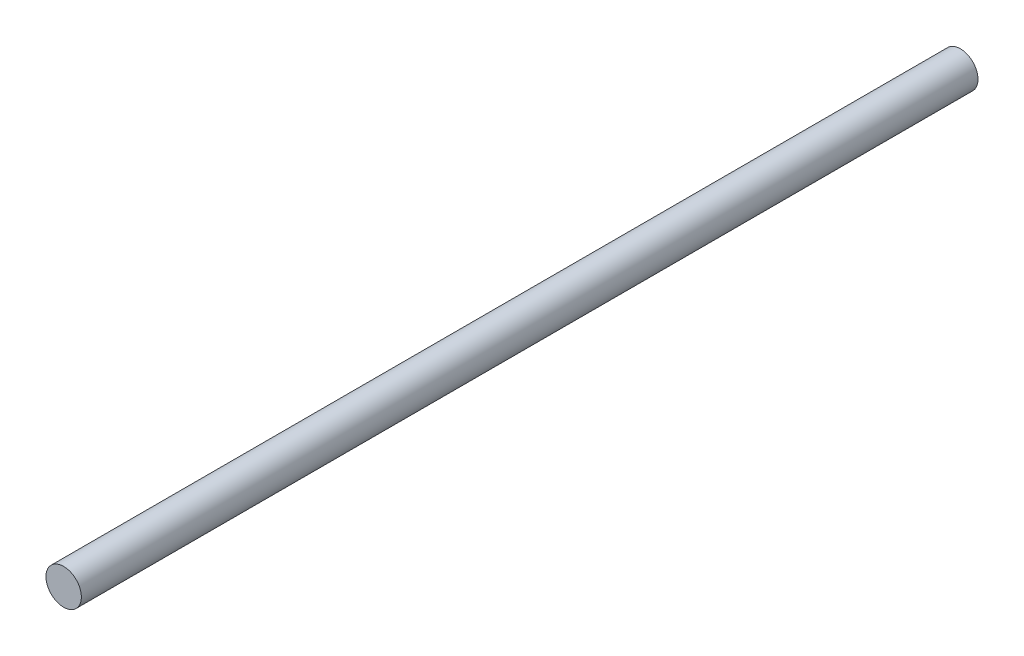
from build123d import *

# Parameters (mm, degrees)
SKETCH1_R           = 4.7625
BOSS_EXTRUDE1_DEPTH = 241.3


with BuildPart() as part:
    # Sketch1 → Boss-Extrude1 (new body)
    with BuildSketch(Plane.XY):
        Circle(SKETCH1_R)
    extrude(amount=BOSS_EXTRUDE1_DEPTH)


solid = part.part
